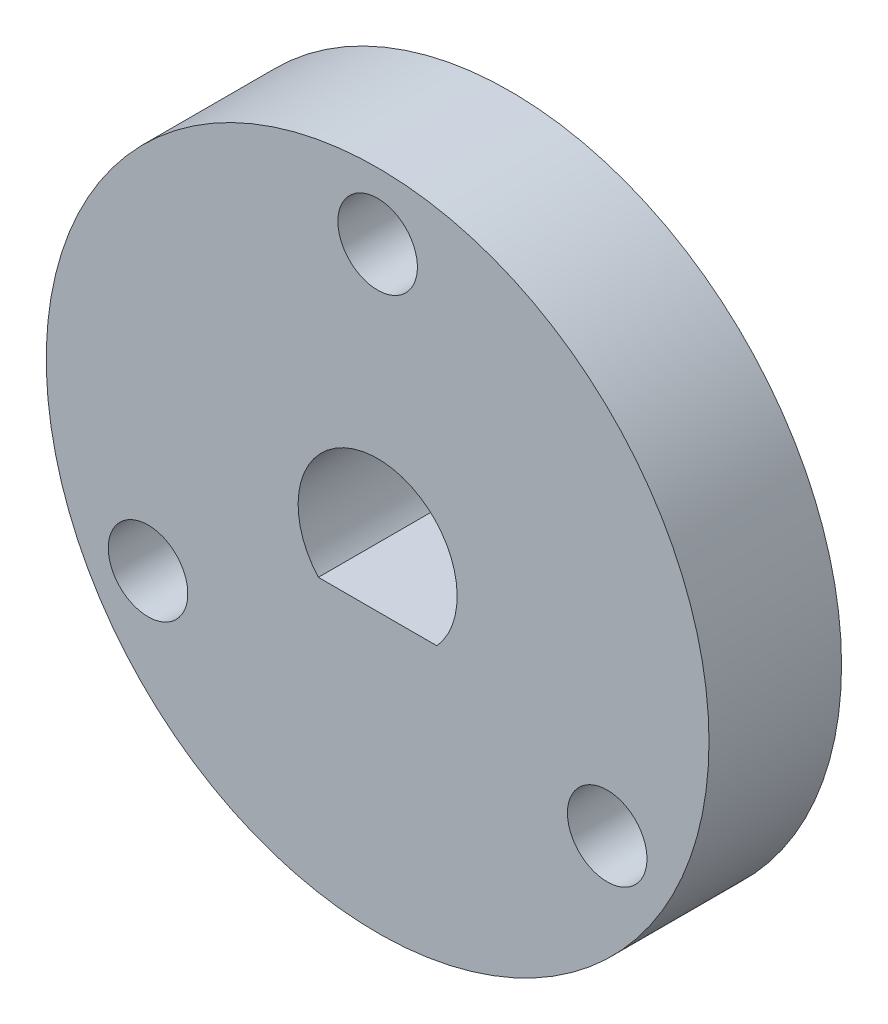
from build123d import *

# Parameters (mm, degrees)
SKETCH1_R           = 25
BOSS_EXTRUDE1_DEPTH = 10
SKETCH2_R           = 3
CUT_EXTRUDE1_DEPTH  = 11


with BuildPart() as part:
    # Sketch1 → Boss-Extrude1 (new body)
    with BuildSketch(Plane.XY):
        Circle(SKETCH1_R)
        with BuildLine():
            Line((-4.472135955, -4), (4.472135955, -4))
            ThreePointArc((4.472135955, -4), (0, 6), (-4.472135955, -4))
        make_face(mode=Mode.SUBTRACT)
    extrude(amount=-BOSS_EXTRUDE1_DEPTH)

    # Sketch2 → Cut-Extrude1 (cut, through all)
    with BuildSketch(Plane(origin=(0, 0, -10), x_dir=(-1, 0, 0), z_dir=(0, 0, -1))):
        with Locations((0, 20)):
            Circle(SKETCH2_R)
        with Locations((17.320508076, -10)):
            Circle(SKETCH2_R)
        with Locations((-17.320508076, -10)):
            Circle(SKETCH2_R)
    extrude(amount=-CUT_EXTRUDE1_DEPTH, mode=Mode.SUBTRACT)


solid = part.part
